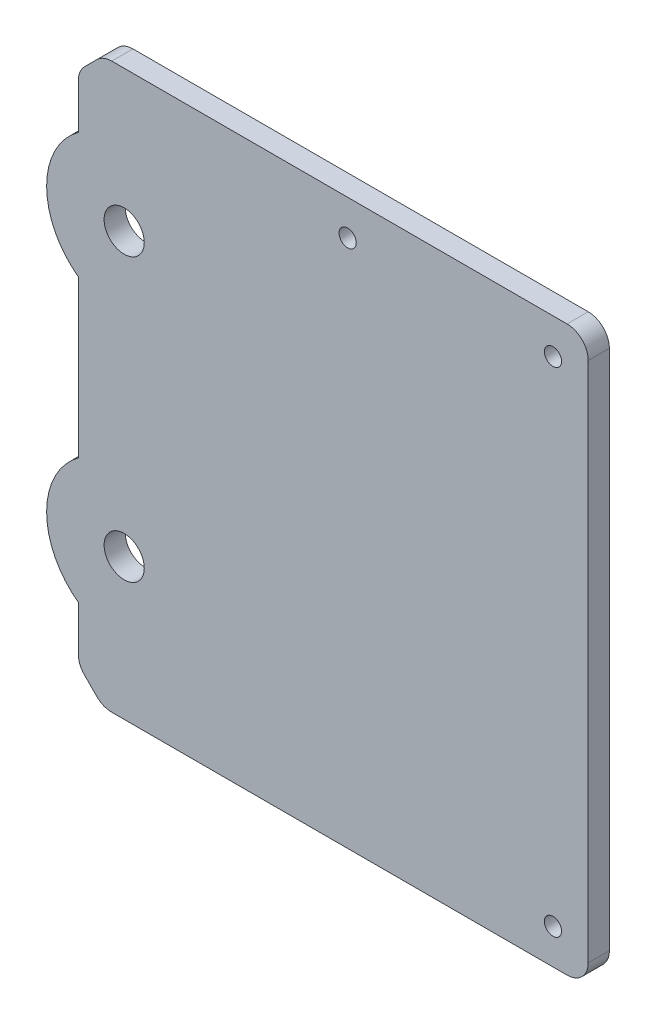
from build123d import *

# Parameters (mm, degrees)
BASE_W                = 72.33
BASE_H                = 80
MAIN_DEPTH            = 3
GEAR_AXIS_HOLES_D     = 5.7
CHAMFER1_SIZE         = 3.5
FILLET6_R             = 3
F_2_CLEARANCE_HOLE2_D = 2.4384
BOSS_EXTRUDE4_DEPTH   = 3


with BuildPart() as part:
    # Base → Main (new body)
    with BuildSketch(Plane.XY):
        with Locations((7.059154817, 0)):
            Rectangle(BASE_W, BASE_H)
    extrude(amount=MAIN_DEPTH)

    # Gear Axis Holes (through all)
    with Locations(Plane(origin=(0, 0, 3), x_dir=(-1, 0, 0), z_dir=(0, 0, 1))):
        with Locations((22.605845183, 20), (22.605845183, -20)):
            Hole(GEAR_AXIS_HOLES_D / 2)

    # Chamfer1
    chamfer1_edges = [part.edges().sort_by_distance(p)[0] for p in [
        (-29.105845183, -40, 1.5),
        (-29.105845183, 40, 1.5),
    ]]
    chamfer(chamfer1_edges, length=CHAMFER1_SIZE)

    # Fillet6
    fillet6_edges = [part.edges().sort_by_distance(p)[0] for p in [
        (-25.605845183, -40, 1.5),
        (-29.105845183, 36.5, 1.5),
        (-29.105845183, -36.5, 1.5),
        (-25.605845183, 40, 1.5),
        (43.224154817, 40, 1.5),
        (43.224154817, -40, 1.5),
    ]]
    fillet(fillet6_edges, radius=FILLET6_R)

    # #2 Clearance Hole2 (through all)
    with Locations(Plane.XY.offset(3)):
        with Locations((9.099154817, 35), (38.224154817, 35), (38.224154817, -35)):
            Hole(F_2_CLEARANCE_HOLE2_D / 2)

    # Sketch24 → Boss-Extrude4 (add)
    with BuildSketch(Plane.XY.offset(3)):
        with BuildLine():
            Line((-29.105845183, 28.874119675), (-29.105845183, 11.125880325))
            ThreePointArc((-29.105845183, 11.125880325), (-33.605845183, 20), (-29.105845183, 28.874119675))
        make_face()
        with BuildLine():
            Line((-29.105845183, -11.125880325), (-29.105845183, -28.874119675))
            ThreePointArc((-29.105845183, -28.874119675), (-33.605845183, -20), (-29.105845183, -11.125880325))
        make_face()
    extrude(amount=-BOSS_EXTRUDE4_DEPTH)


solid = part.part
